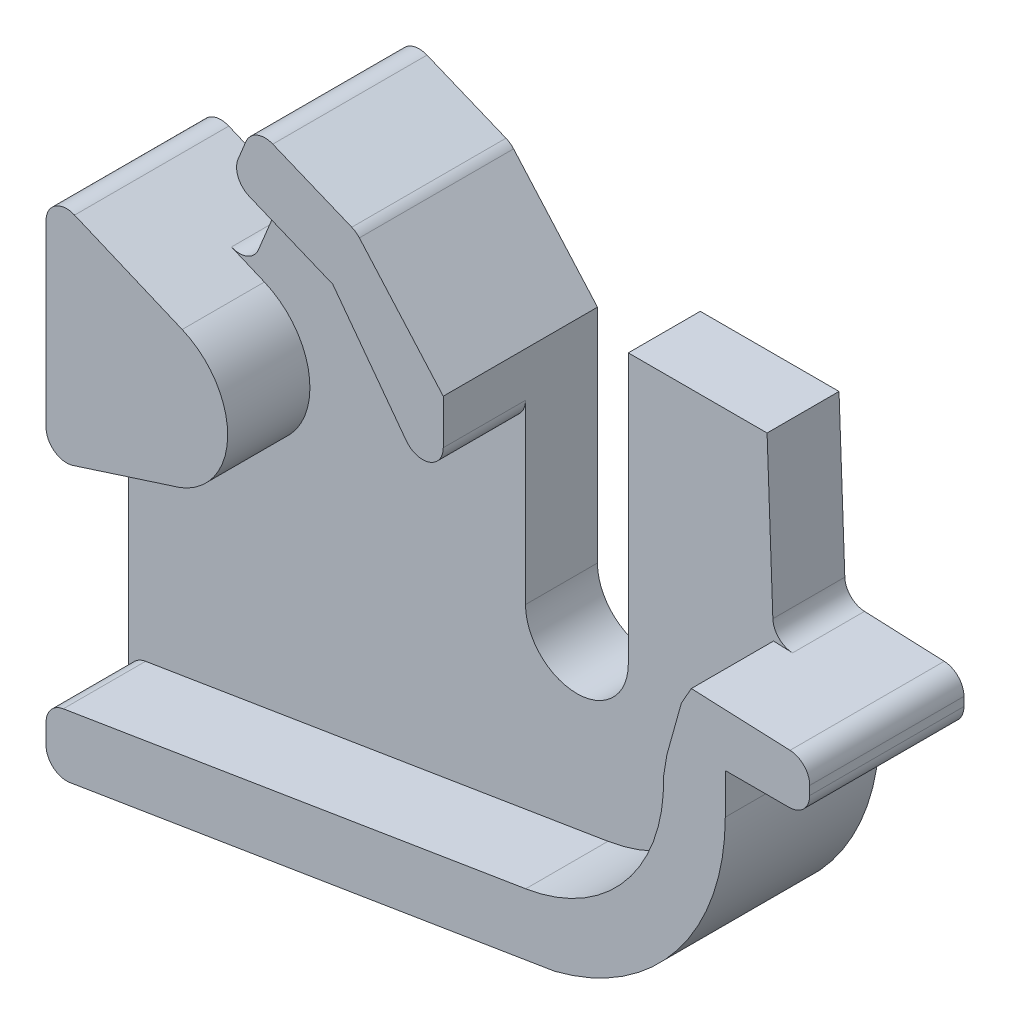
from build123d import *

# Parameters (mm, degrees)
BOSS_EXTRUDE2_DEPTH = 7
BOSS_EXTRUDE3_DEPTH = 15
FILLET1_R           = 2


with BuildPart() as part:
    # Sketch1 → Boss-Extrude2 (new body)
    with BuildSketch(Plane.XY):
        with BuildLine():
            Line((-0.9053830432367259, 24.399326740540857), (-9.372834944506629, 34.00764813303465))
            Line((-9.372834944506627, 34.00764813303465), (-19.338054555793107, 38.10430027910595))
            Line((-19.338054555793107, 38.10430027910595), (-27.64949584669558, 17.88648954074799))
            Line((-27.64949584669558, 17.886489540747988), (-39.54243331524863, 22.895355765149752))
            Line((-39.54243331524863, 22.895355765149752), (-39.54243331524862, -26.68595837588142))
            Line((-39.54243331524862, -26.68595837588142), (9.930508904802714, -18.62730077710855))
            ThreePointArc((9.930508904802696, -18.62730077710854), (21.888607340272763, -10.842166970276782), (26.528997575110665, 2.651209369657105))
            Line((26.528997575110658, 2.6512093696571015), (26.528997575110658, 6.583034036121315))
            Line((26.528997575110658, 6.583034036121315), (34.74430312273597, 6.583034036121314))
            Line((34.74430312273597, 6.583034036121314), (34.74430312273597, 11.35464156582886))
            Line((34.74430312273597, 11.35464156582886), (23.22459679983159, 11.838054320739976))
            Line((23.22459679983159, 11.838054320739976), (22.59461695676328, 29.0520343287084))
            Line((22.59461695676328, 29.052034328708398), (9.094616956763277, 29.052034328708398))
            Line((9.094616956763277, 29.052034328708398), (9.094616956763272, 2.8469015838410883))
            ThreePointArc((9.094616956763272, 2.846901583841089), (4.094616956763275, -2.153098416158908), (-0.9053830432367223, 2.8469015838410887))
            Line((-0.905383043236724, 2.846901583841089), (-0.9053830432367259, 24.399326740540857))
        make_face()
    extrude(amount=BOSS_EXTRUDE2_DEPTH)

    # Sketch1_7 → Boss-Extrude3 (add)
    with BuildSketch(Plane.XY):
        Polygon((-0.9053830432367259, 14.019993611037982), (-0.9053830432367259, 24.399326740540857), (-9.372834944506629, 34.00764813303465), (-19.338054555793107, 38.10430027910595), (-21.61937542853537, 32.55492418123779), (-11.654155817248892, 28.458272035166488), align=None)
        with BuildLine():
            Line((7.118615678125689, -13.085330635476566), (-39.542433315248616, -20.685958375881416))
            Line((-39.54243331524862, -20.685958375881416), (-39.54243331524862, -26.68595837588142))
            Line((-39.54243331524862, -26.68595837588142), (9.930508904802714, -18.62730077710855))
            ThreePointArc((9.930508904802696, -18.62730077710854), (21.888607340272763, -10.842166970276782), (26.528997575110665, 2.651209369657105))
            Line((26.528997575110658, 2.6512093696571015), (26.528997575110658, 6.583034036121315))
            Line((26.528997575110658, 6.583034036121315), (34.74430312273597, 6.583034036121314))
            Line((34.74430312273597, 6.583034036121314), (34.74430312273597, 11.35464156582886))
            Line((34.74430312273597, 11.35464156582886), (23.22459679983159, 11.838054320739976))
            Line((23.224596799831595, 11.838054320739976), (22.25718626662765, 10.122973627008314))
            Line((22.25718626662765, 10.122973627008314), (20.85012579434564, 5.080010210629205))
            Line((20.85012579434564, 5.080010210629205), (20.52330351237285, 3.0772079508363284))
            ThreePointArc((20.523303512372856, 3.0772079508363284), (16.858734444980243, -7.523493754122956), (7.118615678125689, -13.085330635476565))
        make_face()
        with BuildLine():
            Line((-39.54243331524863, 22.895355765149752), (-39.54243331524863, -0.28742000905455))
            Line((-39.54243331524863, -0.28742000905455356), (-27.372162273437738, 3.6262968896541157))
            ThreePointArc((-27.372162273437734, 3.6262968896540997), (-21.8978313295958, 10.087488754460773), (-26.30362524162322, 17.319658525787453))
            Line((-26.30362524162322, 17.319658525787453), (-39.54243331524863, 22.895355765149752))
        make_face()
    extrude(amount=BOSS_EXTRUDE3_DEPTH)

    # Fillet1
    fillet1_edges = [part.edges().sort_by_distance(p)[0] for p in [
        (-39.542433315248616, -20.685958375881416, 11),
        (-39.54243331524863, -0.2874200090545518, 11),
        (-39.54243331524862, -26.68595837588142, 7.5),
        (34.74430312273597, 6.583034036121314, 7.5),
        (34.74430312273597, 11.35464156582886, 7.5),
        (-0.9053830432367262, 14.019993611037982, 11),
        (-21.61937542853537, 32.55492418123779, 11),
        (-19.338054555793107, 38.10430027910595, 7.5),
        (-39.54243331524863, 22.895355765149752, 7.5),
        (-27.64949584669558, 17.886489540747988, 3.5),
        (23.22459679983159, 11.838054320739976, 3.5),
        (-9.372834944506629, 34.00764813303465, 7.5),
    ]]
    fillet(fillet1_edges, radius=FILLET1_R)


solid = part.part
